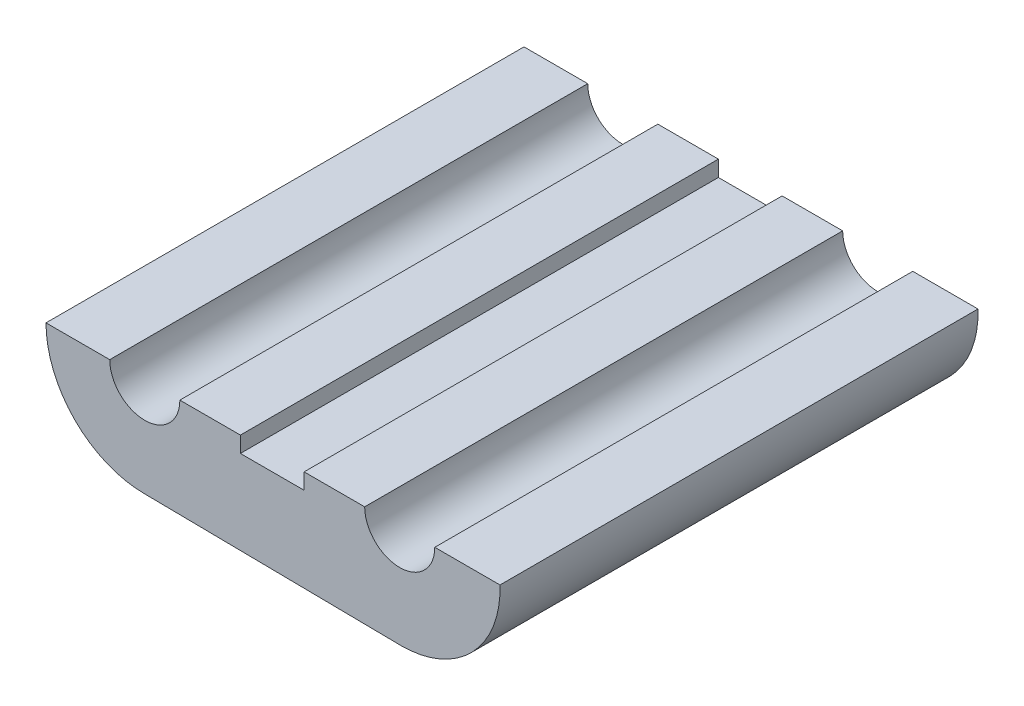
from build123d import *

# Parameters (mm, degrees)
SKETCH1_R           = 1.1
SKETCH1_R_2         = 1.6
BOSS_EXTRUDE1_DEPTH = 15
SKETCH3_R           = 1.6
CUT_EXTRUDE1_DEPTH  = 15
SKETCH5_W           = 2
SKETCH5_H           = 0.5
CUT_EXTRUDE2_DEPTH  = 16


with BuildPart() as part:
    # Sketch1 → Boss-Extrude1 (new body)
    with BuildSketch(Plane.XY):
        with BuildLine():
            Line((-1.61243197, 5.01974999), (-5.34022711, 2.600340269))
            ThreePointArc((-5.34022711, 2.600340269), (-6.625018483, -0.880041239), (-3.652556975, -3.1))
            Line((-3.652556975, -3.1), (4.395993446, -3.201847309))
            ThreePointArc((4.395993446, -3.201847309), (7.362670385, -1.001195929), (6.117333323, 2.476328214))
            Line((6.117333323, 2.476328214), (2.346418367, 4.994010285))
            ThreePointArc((2.346418367, 4.994010285), (0.370849058, 5.59992391), (-1.61243197, 5.01974999))
        make_face()
        with Locations((4.347443025, 0)):
            Circle(SKETCH1_R, mode=Mode.SUBTRACT)
        with Locations((0.347443025, 2)):
            Circle(SKETCH1_R_2, mode=Mode.SUBTRACT)
        with Locations((-3.652556975, 0)):
            Circle(SKETCH1_R, mode=Mode.SUBTRACT)
    extrude(amount=BOSS_EXTRUDE1_DEPTH)

    # Sketch3 → Cut-Extrude1 (cut)
    with BuildSketch(Plane.XY.offset(15)):
        with BuildLine():
            ThreePointArc((-4.752556975, 0), (-3.652556975, 1.1), (-2.552556975, 0))
            Line((-2.552556975, 0), (3.247443025, 0))
            ThreePointArc((3.247443025, 0), (4.347443025, 1.1), (5.447443025, 0))
            Line((5.447443025, 0), (7.49431995, 0))
            ThreePointArc((7.49431995, 0), (7.105300804, 1.404689659), (6.117333323, 2.476328214))
            Line((6.117333323, 2.476328214), (2.346418367, 4.994010285))
            ThreePointArc((2.346418367, 4.994010285), (0.370849058, 5.59992391), (-1.61243197, 5.01974999))
            Line((-1.61243197, 5.01974999), (-5.34022711, 2.600340269))
            ThreePointArc((-5.34022711, 2.600340269), (-6.376687792, 1.479564561), (-6.752556975, 0))
            Line((-6.752556975, 0), (-4.752556975, 0))
        make_face()
        with Locations((0.347443025, 2)):
            Circle(SKETCH3_R, mode=Mode.SUBTRACT)
    extrude(amount=-CUT_EXTRUDE1_DEPTH, mode=Mode.SUBTRACT)

    # Sketch5 → Cut-Extrude2 (cut, through all)
    with BuildSketch(Plane.XY.offset(15)):
        with Locations((0.347443025, -0.25)):
            Rectangle(SKETCH5_W, SKETCH5_H)
    extrude(amount=-CUT_EXTRUDE2_DEPTH, mode=Mode.SUBTRACT)


solid = part.part
